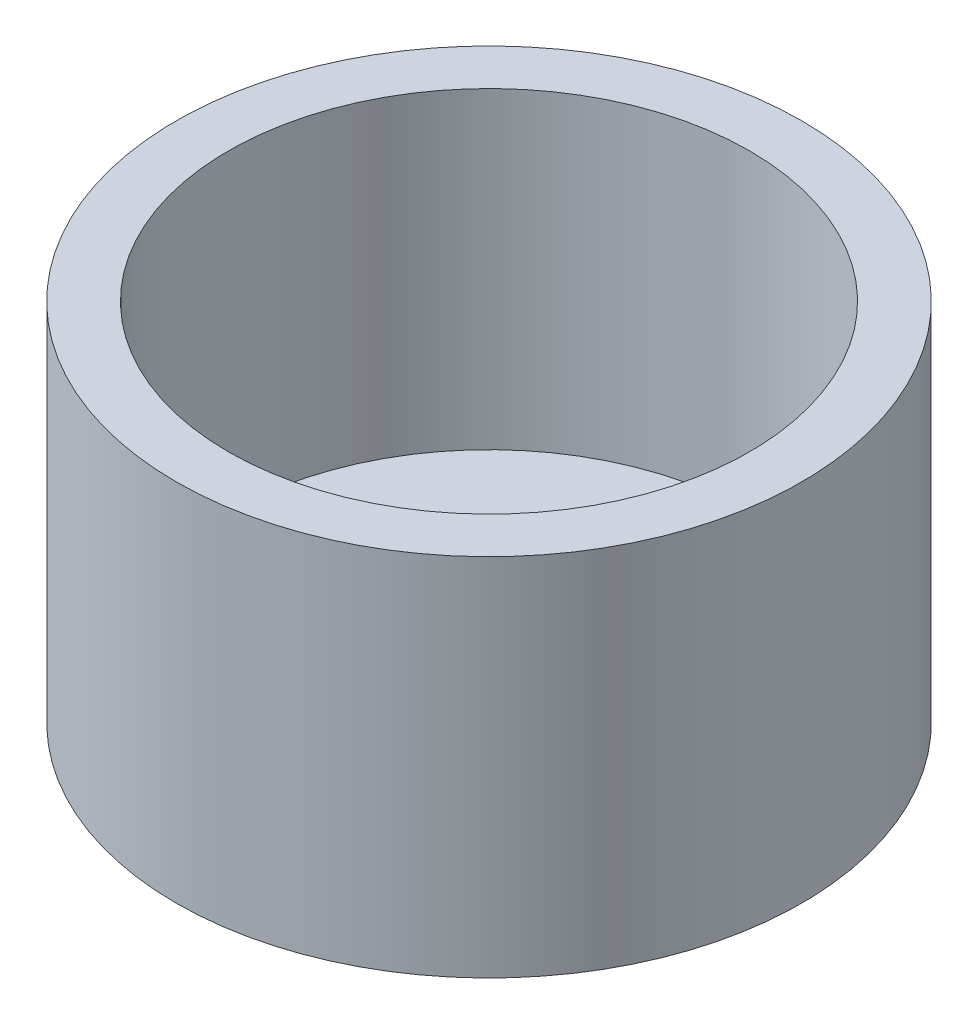
from build123d import *

# Parameters (mm, degrees)
SKETCH1_R           = 15
BOSS_EXTRUDE1_DEPTH = 17.5
SKETCH2_R           = 12.5
CUT_EXTRUDE1_DEPTH  = 15


with BuildPart() as part:
    # Sketch1 → Boss-Extrude1 (new body)
    with BuildSketch(Plane(origin=(0, 0, 0), x_dir=(1, 0, 0), z_dir=(0, 1, 0))):
        with Locations((-5.425115689, 4.310704304)):
            Circle(SKETCH1_R)
    extrude(amount=BOSS_EXTRUDE1_DEPTH)

    # Sketch2 → Cut-Extrude1 (cut)
    with BuildSketch(Plane(origin=(0, 17.5, 0), x_dir=(1, 0, 0), z_dir=(0, 1, 0))):
        with Locations((-5.425115689, 4.310704304)):
            Circle(SKETCH2_R)
    extrude(amount=-CUT_EXTRUDE1_DEPTH, mode=Mode.SUBTRACT)


solid = part.part
